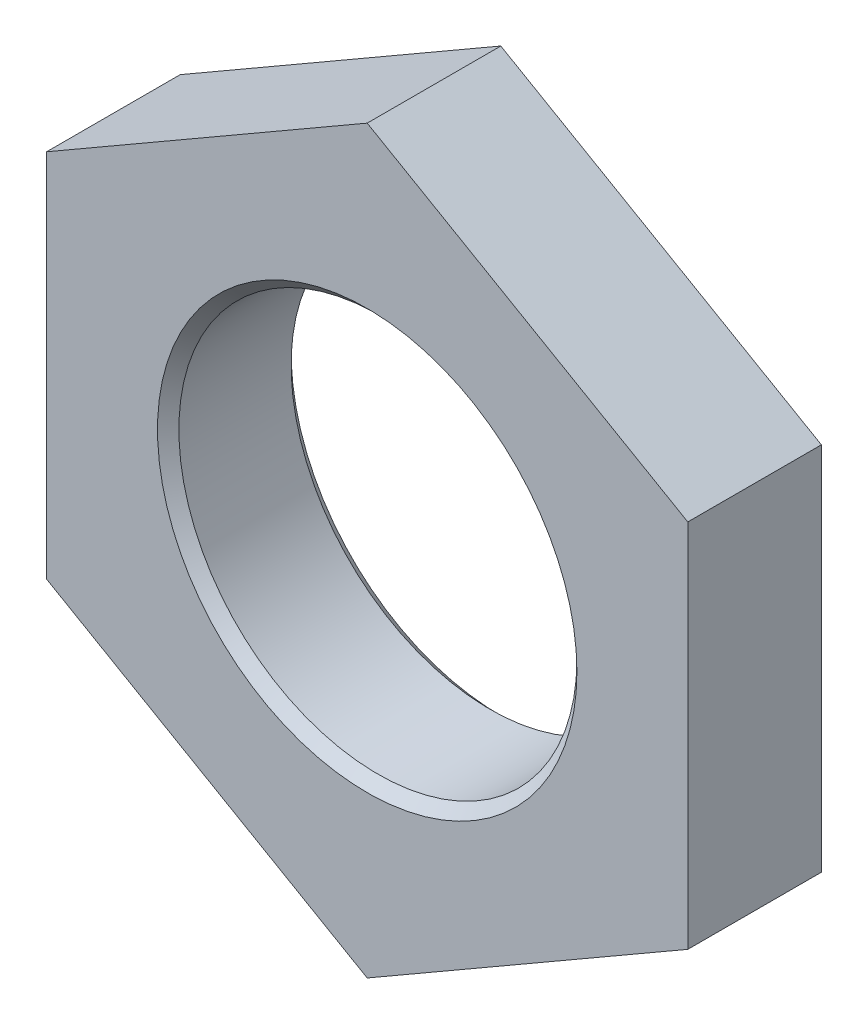
from build123d import *

# Parameters (mm, degrees)
EXTRUDE_1_DEPTH     = 2.5
SKETCH_3_R          = 3.724956963
CUT_EXTRUDE_1_DEPTH = 6.5
CHAMFER_1_SIZE      = 0.2


with BuildPart() as part:
    # 草图2 → 凸台-拉伸1 (new body)
    with BuildSketch(Plane.XY):
        Polygon((0, 6.92820323), (-6, 3.464101615), (-6, -3.464101615), (0, -6.92820323), (6, -3.464101615), (6, 3.464101615), align=None)
    extrude(amount=EXTRUDE_1_DEPTH)

    # 草图3 → 切除-拉伸1 (cut)
    with BuildSketch(Plane(origin=(0, 0, 0), x_dir=(-1, 0, 0), z_dir=(0, 0, -1))):
        Circle(SKETCH_3_R)
    extrude(amount=-CUT_EXTRUDE_1_DEPTH, mode=Mode.SUBTRACT)

    # 倒角1
    chamfer_1_edges = [part.edges().sort_by_distance(p)[0] for p in [
        (3.724956963, 0, 2.5),
        (3.724956963, 0, 0),
    ]]
    chamfer(chamfer_1_edges, length=CHAMFER_1_SIZE)


solid = part.part
